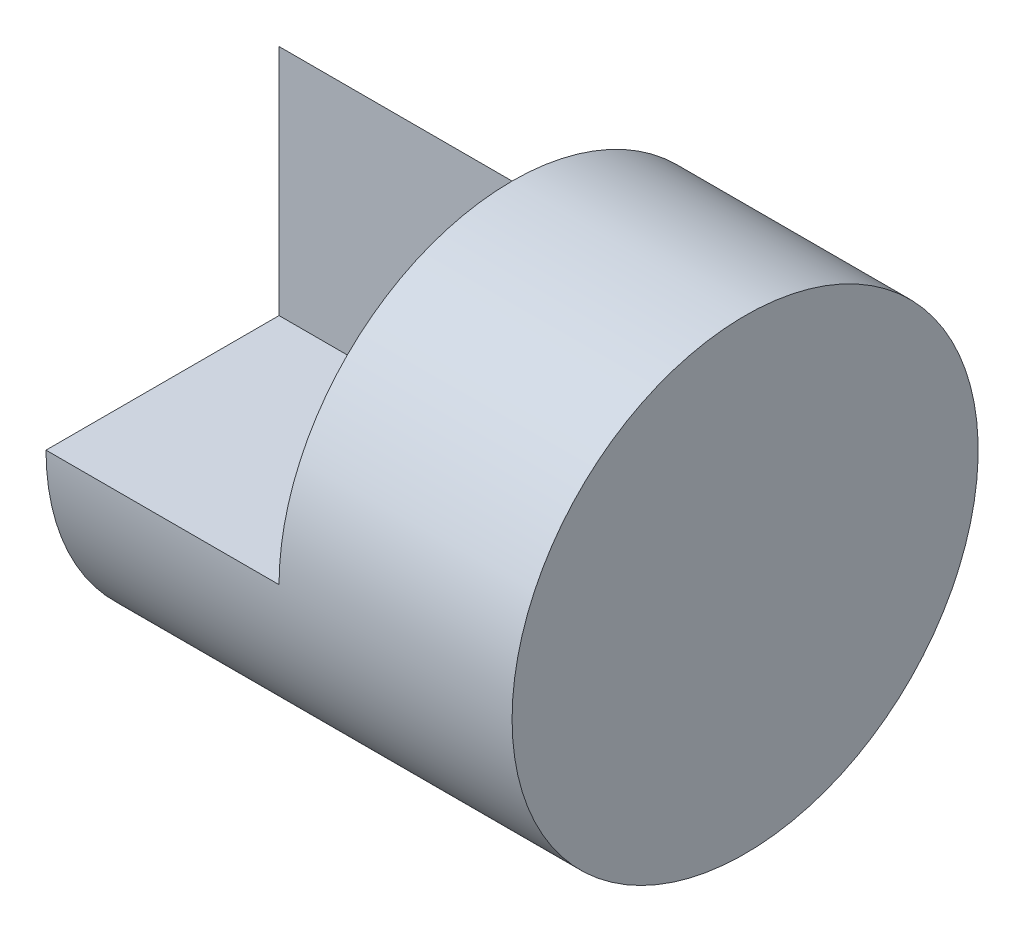
from build123d import *

# Parameters (mm, degrees)
SKETCH1_W           = 4
SKETCH1_H           = 4
BOSS_EXTRUDE1_DEPTH = 4
SKETCH2_W           = 2
SKETCH2_H           = 2
CUT_EXTRUDE1_DEPTH  = 2
SKETCH3_R           = 2.828427125
SKETCH3_R_2         = 2
CUT_EXTRUDE2_DEPTH  = 30


with BuildPart() as part:
    # Sketch1 → Boss-Extrude1 (new body)
    with BuildSketch(Plane(origin=(0, 0, 0), x_dir=(1, 0, 0), z_dir=(0, 1, 0))):
        Rectangle(SKETCH1_W, SKETCH1_H)
    extrude(amount=BOSS_EXTRUDE1_DEPTH)

    # Sketch2 → Cut-Extrude1 (cut)
    with BuildSketch(Plane.ZY.offset(2)):
        Polygon((-2, 4), (-2, 2), (0, 4), align=None)
        with Locations((1, 3)):
            Rectangle(SKETCH2_W, SKETCH2_H)
    extrude(amount=-CUT_EXTRUDE1_DEPTH, mode=Mode.SUBTRACT)

    # Sketch3 → Cut-Extrude2 (cut, symmetric)
    with BuildSketch(Plane.ZY):
        with Locations((0, 2)):
            Circle(SKETCH3_R)
        with Locations((0, 2)):
            Circle(SKETCH3_R_2, mode=Mode.SUBTRACT)
    extrude(amount=CUT_EXTRUDE2_DEPTH, both=True, mode=Mode.SUBTRACT)


solid = part.part
